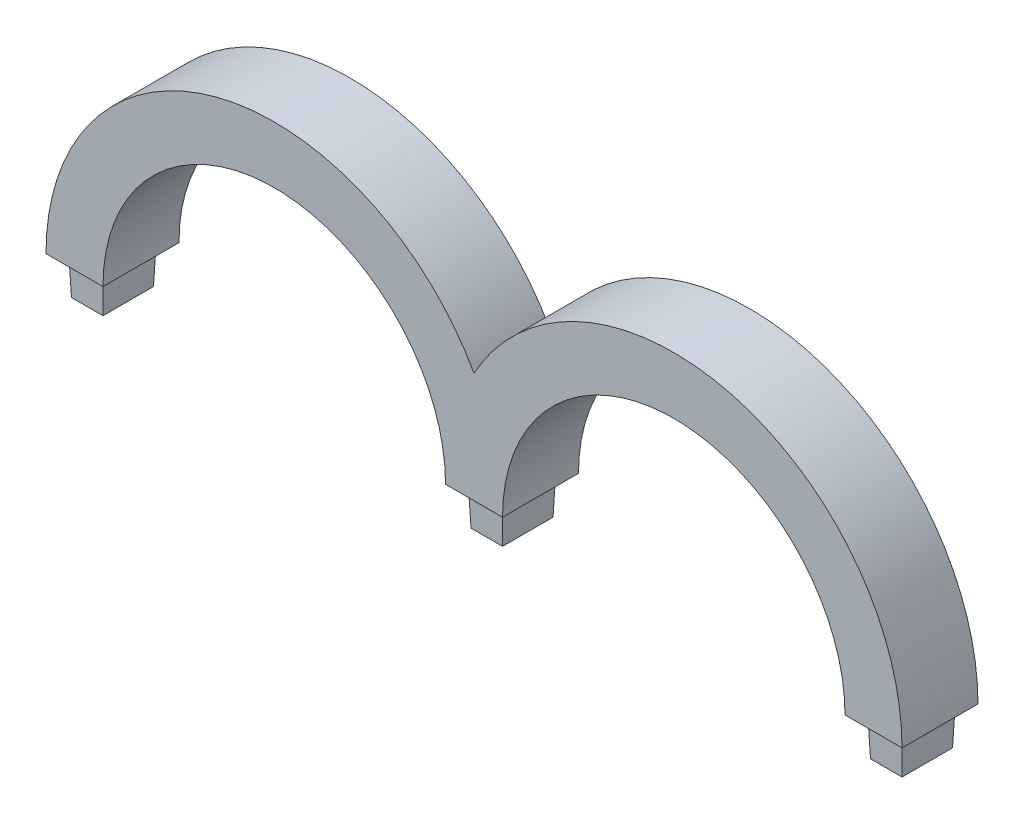
from build123d import *

# Parameters (mm, degrees)
BOSS_EXTRUDE1_DEPTH = 20
SKETCH3_W           = 9
SKETCH3_H           = 14
BOSS_EXTRUDE2_DEPTH = 10
BOSS_EXTRUDE2_TAPER = 2


with BuildPart() as part:
    # Sketch2 → Boss-Extrude1 (new body)
    with BuildSketch(Plane.XY):
        with BuildLine():
            Line((45.085, 0), (60.085, 0))
            ThreePointArc((60.085, 0), (105.17, 45.085), (150.255, 0))
            Line((150.255, 0), (165.255, 0))
            ThreePointArc((165.255, 0), (120.18062124, 58.179794388), (52.585, 29.069313717))
            ThreePointArc((52.585, 29.069313717), (-15.01062124, 58.179794388), (-60.085, 0))
            Line((-60.085, 0), (-45.085, 0))
            ThreePointArc((-45.085, 0), (0, 45.085), (45.085, 0))
        make_face()
    extrude(amount=BOSS_EXTRUDE1_DEPTH)

    # Sketch3 → Boss-Extrude2 (add)
    with BuildSketch(Plane.XZ):
        with Locations((-52.585, 10)):
            Rectangle(SKETCH3_W, SKETCH3_H)
        with Locations((52.585, 10)):
            Rectangle(SKETCH3_W, SKETCH3_H)
        with Locations((157.755, 10)):
            Rectangle(SKETCH3_W, SKETCH3_H)
    extrude(amount=BOSS_EXTRUDE2_DEPTH, taper=BOSS_EXTRUDE2_TAPER)


solid = part.part
